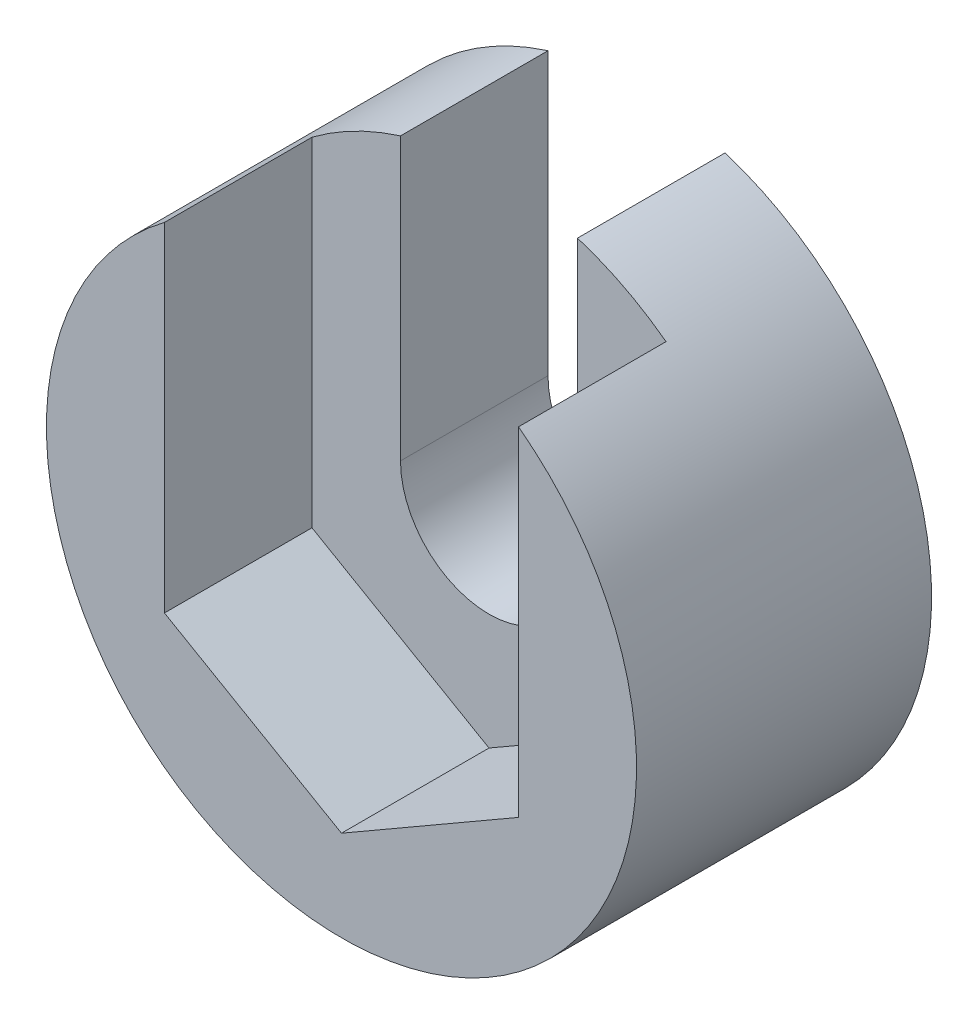
from build123d import *

# Parameters (mm, degrees)
SZKIC1_R                                 = 5
DODANIE_WYCI_GNI_CIE1_DEPTH              = 5
WYTNIJ_WYCI_GNI_CIE3_DEPTH               = 2.5
OTWORY_USTALAJ_CE_3_0MMCLEARANCE_1_D     = 3
OTWORY_USTALAJ_CE_3_0MMCLEARANCE_1_DEPTH = 7.25
OTWORY_USTALAJ_CE_3_0MMCLEARANCE_1_TIP   = 0.901290929
SZKIC19_W                                = 6
SZKIC19_H                                = 3.662813391
WYTNIJ_WYCI_GNI_CIE8_DEPTH               = 2.5
SZKIC20_W                                = 3
SZKIC20_H                                = 6.977009587
WYTNIJ_WYCI_GNI_CIE9_DEPTH               = 2.5


with BuildPart() as part:
    # Szkic1 → Dodanie-wyciągnięcie1 (new body)
    with BuildSketch(Plane.XY):
        Circle(SZKIC1_R)
    extrude(amount=DODANIE_WYCI_GNI_CIE1_DEPTH)

    # Szkic10 → Wytnij-wyciągnięcie3 (cut)
    with BuildSketch(Plane.XY.offset(5)):
        Polygon((0, 3.464101615), (-3, 1.732050808), (-3, -1.732050808), (0, -3.464101615), (3, -1.732050808), (3, 1.732050808), align=None)
    extrude(amount=-WYTNIJ_WYCI_GNI_CIE3_DEPTH, mode=Mode.SUBTRACT)

    # Otwory ustalające Ø3.0mmClearance 1
    with Locations(Plane.XY.offset(2.5)):
        with Locations((0, 0)):
            Hole(OTWORY_USTALAJ_CE_3_0MMCLEARANCE_1_D / 2, depth=OTWORY_USTALAJ_CE_3_0MMCLEARANCE_1_DEPTH)
            with Locations((0, 0, -(OTWORY_USTALAJ_CE_3_0MMCLEARANCE_1_DEPTH + OTWORY_USTALAJ_CE_3_0MMCLEARANCE_1_TIP / 2))):  # 118° drill point
                Cone(0, OTWORY_USTALAJ_CE_3_0MMCLEARANCE_1_D / 2, OTWORY_USTALAJ_CE_3_0MMCLEARANCE_1_TIP, mode=Mode.SUBTRACT)

    # Szkic19 → Wytnij-wyciągnięcie8 (cut)
    with BuildSketch(Plane.XY.offset(5)):
        with Locations((0, 3.563457504)):
            Rectangle(SZKIC19_W, SZKIC19_H)
    extrude(amount=-WYTNIJ_WYCI_GNI_CIE8_DEPTH, mode=Mode.SUBTRACT)

    # Szkic20 → Wytnij-wyciągnięcie9 (cut)
    with BuildSketch(Plane.XY.offset(2.5)):
        with Locations((0, 3.488504794)):
            Rectangle(SZKIC20_W, SZKIC20_H)
    extrude(amount=-WYTNIJ_WYCI_GNI_CIE9_DEPTH, mode=Mode.SUBTRACT)


solid = part.part
